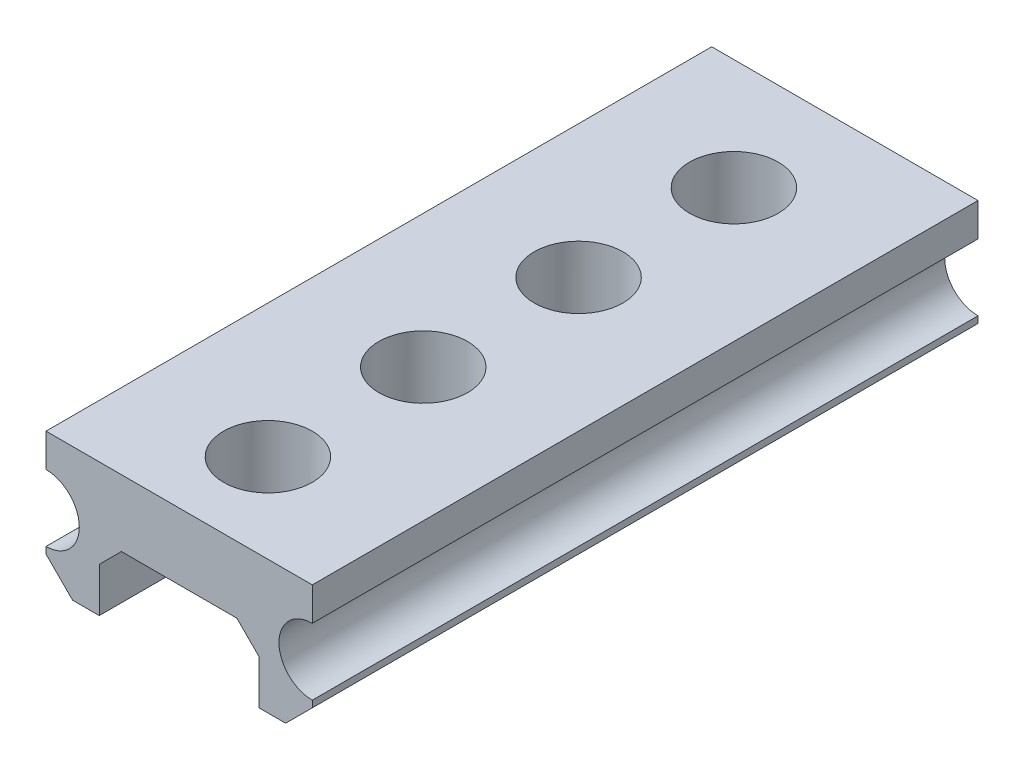
from build123d import *

# Parameters (mm, degrees)
SKETCH1_W           = 6
SKETCH1_H           = 3
BOSS_EXTRUDE1_DEPTH = 15
SKETCH2_R           = 0.75
CUT_EXTRUDE1_DEPTH  = 20
CHAMFER1_SIZE       = 0.6
SKETCH3_R           = 1
CUT_EXTRUDE2_DEPTH  = 20
LPATTERN1_COUNT     = 4
LPATTERN1_PITCH     = 3.5
SKETCH4_W           = 3.6
SKETCH4_H           = 1.5
CUT_EXTRUDE3_DEPTH  = 20
CHAMFER2_SIZE       = 0.5


with BuildPart() as part:
    # Sketch1 → Boss-Extrude1 (new body)
    with BuildSketch(Plane.XY):
        Rectangle(SKETCH1_W, SKETCH1_H)
    extrude(amount=BOSS_EXTRUDE1_DEPTH)

    # Sketch2 → Cut-Extrude1 (cut)
    with BuildSketch(Plane.XY.offset(15)):
        with Locations((3, 0)):
            Circle(SKETCH2_R)
        with Locations((-3, 0)):
            Circle(SKETCH2_R)
    extrude(amount=-CUT_EXTRUDE1_DEPTH, mode=Mode.SUBTRACT)

    # Chamfer1
    chamfer1_edges = [part.edges().sort_by_distance(p)[0] for p in [
        (3, -1.5, 7.5),
        (-3, -1.5, 7.5),
    ]]
    chamfer(chamfer1_edges, length=CHAMFER1_SIZE)

    # Sketch3 → Cut-Extrude2 (cut)
    with BuildSketch(Plane(origin=(0, 1.5, 0), x_dir=(1, 0, 0), z_dir=(0, 1, 0))):
        with Locations((0, -2.5)):
            Circle(SKETCH3_R)
    cut_extrude2 = extrude(amount=-CUT_EXTRUDE2_DEPTH, mode=Mode.SUBTRACT)

    # LPattern1: Cut-Extrude2 ×4
    with Locations(*[(0, 0, i * LPATTERN1_PITCH) for i in range(1, LPATTERN1_COUNT)]):
        add(cut_extrude2, mode=Mode.SUBTRACT)

    # Sketch4 → Cut-Extrude3 (cut)
    with BuildSketch(Plane(origin=(0, 0, 0), x_dir=(-1, 0, 0), z_dir=(0, 0, -1))):
        with Locations((0, -0.75)):
            Rectangle(SKETCH4_W, SKETCH4_H)
    extrude(amount=-CUT_EXTRUDE3_DEPTH, mode=Mode.SUBTRACT)

    # Chamfer2
    chamfer2_edges = [part.edges().sort_by_distance(p)[0] for p in [
        (1.8, 0, 7.5),
        (-1.8, 0, 7.5),
    ]]
    chamfer(chamfer2_edges, length=CHAMFER2_SIZE)


solid = part.part
